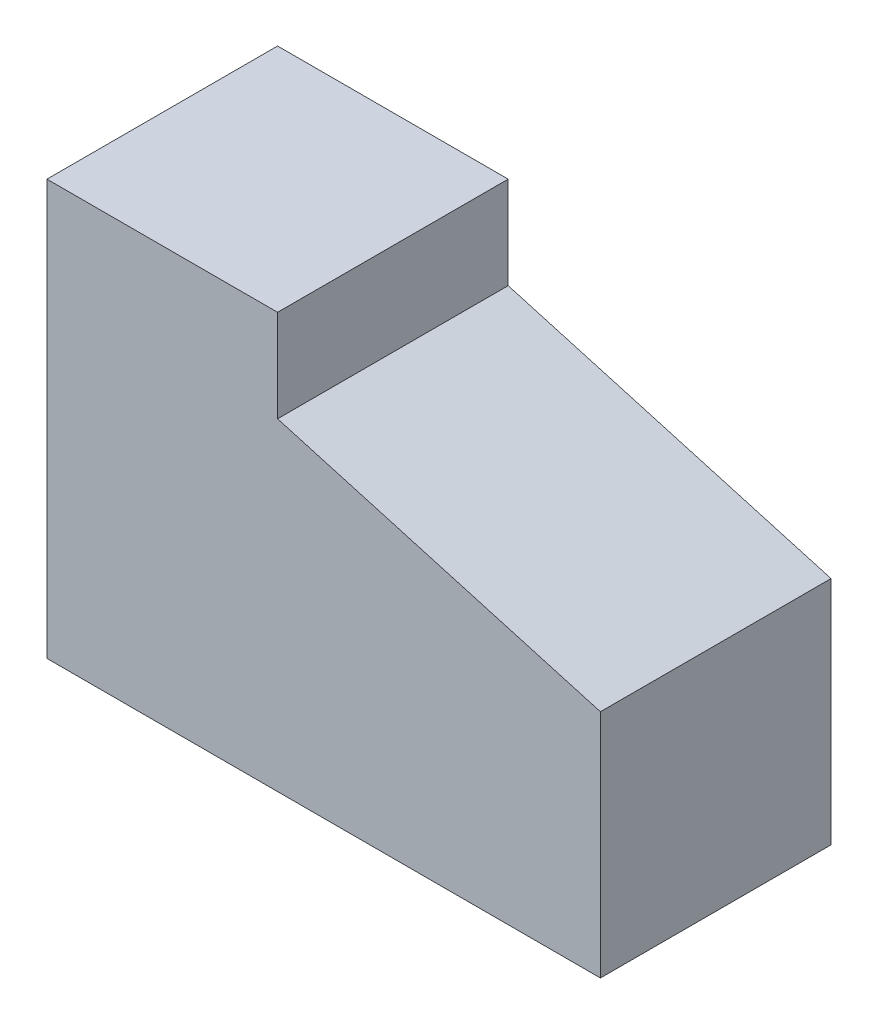
from build123d import *

# Parameters (mm, degrees)
BOSS_EXTRUDE1_DEPTH = 127


with BuildPart() as part:
    # Sketch1 → Boss-Extrude1 (new body)
    with BuildSketch(Plane.XY):
        Polygon((127, 228.6), (127, 177.8), (304.8, 127), (304.8, 0), (0, 0), (0, 228.6), align=None)
    extrude(amount=BOSS_EXTRUDE1_DEPTH)


solid = part.part
